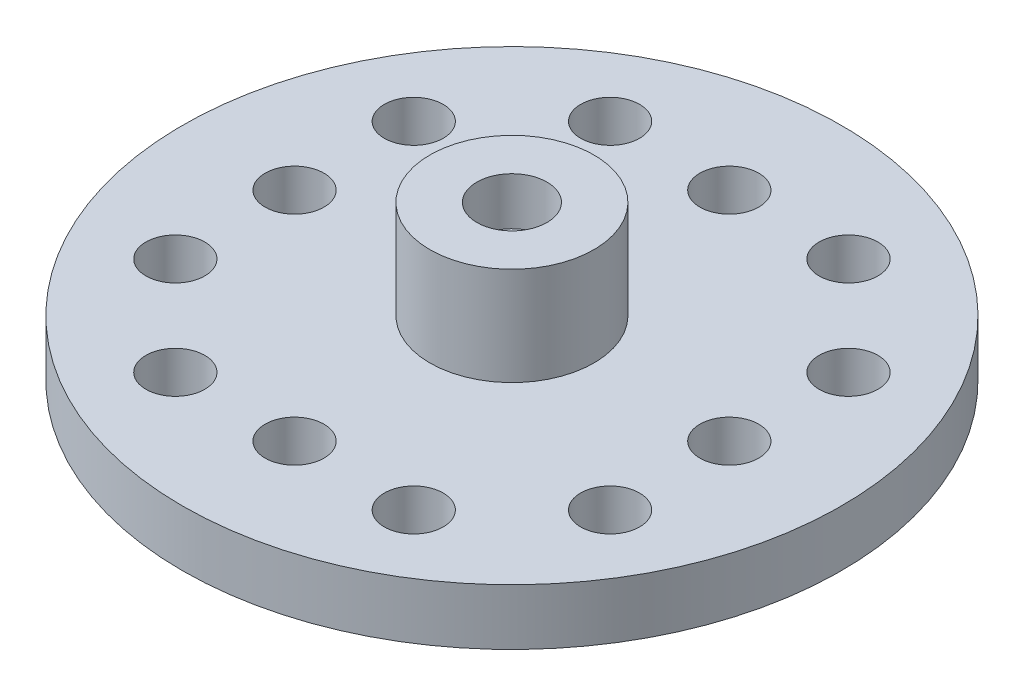
from build123d import *

# Parameters (mm, degrees)
SKETCH_1_R               = 23.5
EXTRUDE_1_DEPTH          = 4
SKETCH_2_R               = 5.85
EXTRUDE_2_DEPTH          = 7
SKETCH_3_R               = 2.5
CUT_EXTRUDE_1_DEPTH      = 3.4
SKETCH_4_R               = 2.1
CUT_EXTRUDE_2_DEPTH      = 5
PATTERN_CIRCULAR_1_COUNT = 4
SKETCH_5_R               = 2
CUT_EXTRUDE_3_DEPTH      = 8.6


with BuildPart() as part:
    # 草圖1 → 填料-伸長1 (new body)
    with BuildSketch(Plane(origin=(0, 0, 0), x_dir=(1, 0, 0), z_dir=(0, 1, 0))):
        Circle(SKETCH_1_R)
    extrude(amount=EXTRUDE_1_DEPTH)

    # 草圖2 → 填料-伸長2 (add)
    with BuildSketch(Plane(origin=(0, 4, 0), x_dir=(1, 0, 0), z_dir=(0, 1, 0))):
        Circle(SKETCH_2_R)
    extrude(amount=EXTRUDE_2_DEPTH)

    # 草圖3 → 除料-伸長1 (cut)
    with BuildSketch(Plane(origin=(0, 11, 0), x_dir=(1, 0, 0), z_dir=(0, 1, 0))):
        Circle(SKETCH_3_R)
    extrude(amount=-CUT_EXTRUDE_1_DEPTH, mode=Mode.SUBTRACT)

    # 草圖4 → 除料-伸長2 (cut, through all)
    with BuildSketch(Plane(origin=(0, 4, 0), x_dir=(1, 0, 0), z_dir=(0, 1, 0))):
        with Locations((-15.5, 0)):
            Circle(SKETCH_4_R)
        with Locations((-15.5, 8.5)):
            Circle(SKETCH_4_R)
        with Locations((-15.5, -8.5)):
            Circle(SKETCH_4_R)
    cut_extrude_2 = extrude(amount=-CUT_EXTRUDE_2_DEPTH, mode=Mode.SUBTRACT)

    # 環狀複製排列1: 除料-伸長2 ×4 about axis
    pattern_circular_1_axis = Axis((0, 0, 0), (0, 1, 0))
    for i in range(1, PATTERN_CIRCULAR_1_COUNT):
        add(cut_extrude_2.rotate(pattern_circular_1_axis, i * 360 / PATTERN_CIRCULAR_1_COUNT), mode=Mode.SUBTRACT)

    # 草圖5 → 除料-伸長3 (cut, through all)
    with BuildSketch(Plane(origin=(0, 7.6, 0), x_dir=(1, 0, 0), z_dir=(0, 1, 0))):
        Circle(SKETCH_5_R)
    extrude(amount=-CUT_EXTRUDE_3_DEPTH, mode=Mode.SUBTRACT)


solid = part.part
